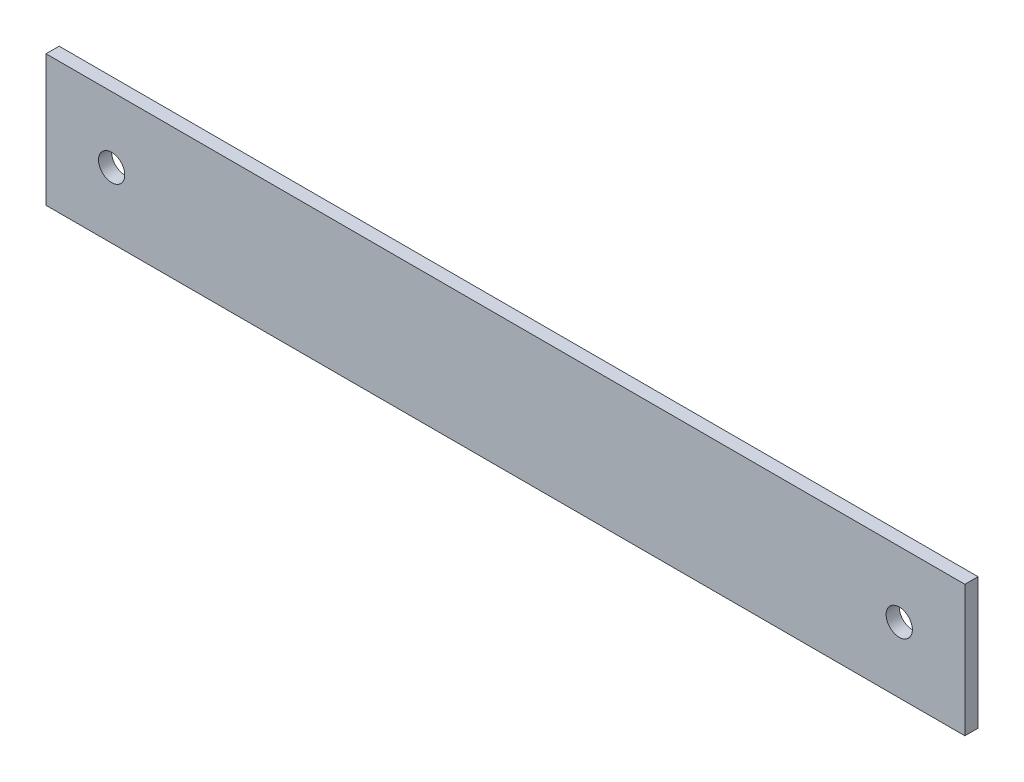
from build123d import *

# Parameters (mm, degrees)
SKETCH1_W           = 140
SKETCH1_H           = 20
BOSS_EXTRUDE1_DEPTH = 2
SKETCH2_R           = 2
CUT_EXTRUDE1_DEPTH  = 3


with BuildPart() as part:
    # Sketch1 → Boss-Extrude1 (new body)
    with BuildSketch(Plane.XY):
        Rectangle(SKETCH1_W, SKETCH1_H)
    extrude(amount=BOSS_EXTRUDE1_DEPTH)

    # Sketch2 → Cut-Extrude1 (cut, through all)
    with BuildSketch(Plane.XY.offset(2)):
        with Locations((-60, 0)):
            Circle(SKETCH2_R)
        with Locations((60, 0)):
            Circle(SKETCH2_R)
    extrude(amount=-CUT_EXTRUDE1_DEPTH, mode=Mode.SUBTRACT)


solid = part.part
